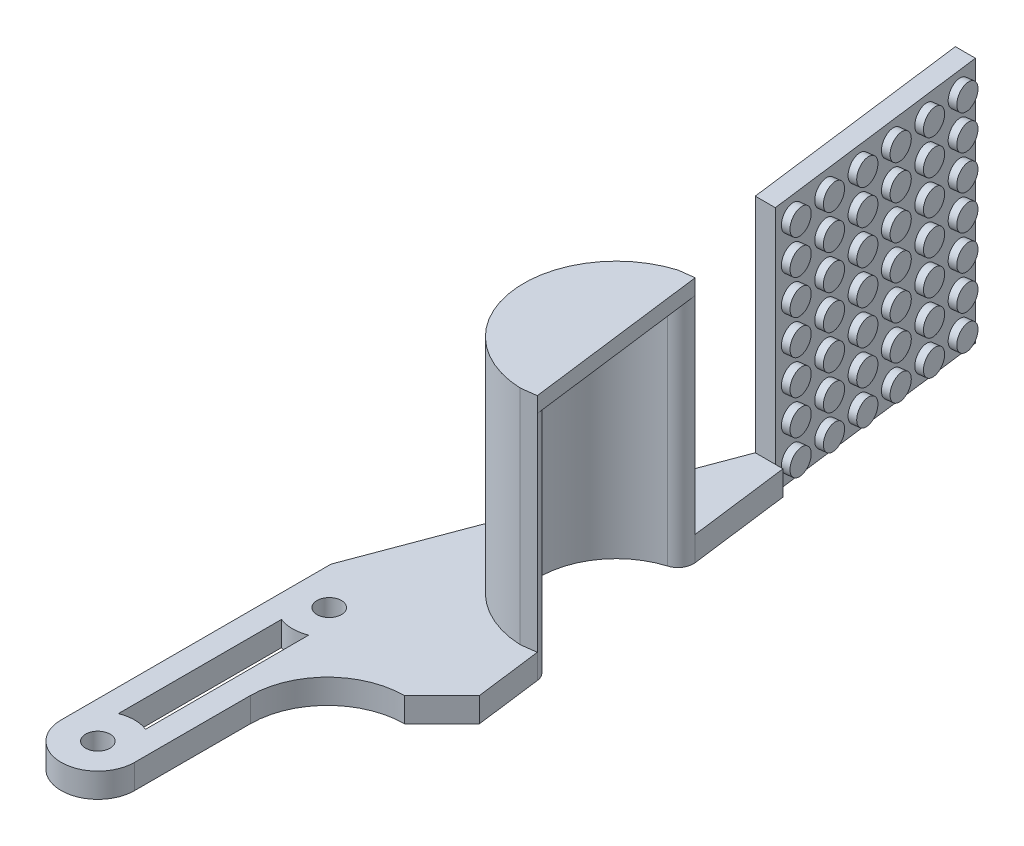
from build123d import *
from build123d.topology import SkipClean

# Parameters (mm, degrees)
CROQUIS1_R              = 1.5875
SALIENTE_EXTRUIR1_DEPTH = 3.175
CORTAR_EXTRUIR1_DEPTH   = 3.175
CORTAR_EXTRUIR3_DEPTH   = 10
CROQUIS4_R              = 10
CORTAR_EXTRUIR4_DEPTH   = 10
REDONDEO1_R             = 2
BOSS_EXTRUDE1_DEPTH     = 26.82
BOSS_EXTRUDE2_DEPTH     = 2
BOSS_EXTRUDE3_DEPTH     = 31.995
SKETCH5_R               = 1.59
BOSS_EXTRUDE4_DEPTH     = 1


with BuildPart() as part:
    # Croquis1 → Saliente-Extruir1 (new body)
    with BuildSketch(Plane(origin=(0, 0, 0), x_dir=(1, 0, 0), z_dir=(0, 1, 0))):
        with BuildLine():
            Line((-12.5, 0), (-12.5, -40))
            Line((-12.5, -40), (-2.975, -40))
            Line((-2.975, -40), (-2.975, -20))
            ThreePointArc((-2.975, -20), (-0.046067812, -12.928932188), (7.025, -10))
            Line((7.025, -10), (12.5, -10))
            Line((12.5, -10), (12.5, 40))
            Line((12.5, 40), (2.5, 40))
            Line((2.5, 40), (-12.5, 0))
        make_face()
        with Locations(Location((-7.7375, -5, 0), (0, 0, 270))):
            Circle(CROQUIS1_R, mode=Mode.SUBTRACT)
        with Locations(Location((-7.7375, -35, 0), (0, 0, 270))):
            Circle(CROQUIS1_R, mode=Mode.SUBTRACT)
    extrude(amount=SALIENTE_EXTRUIR1_DEPTH)

    # Croquis2 → Cortar-Extruir1 (cut)
    with BuildSketch(Plane(origin=(0, 3.175, 0), x_dir=(1, 0, 0), z_dir=(0, 1, 0))):
        Polygon((12.5, -10), (6.1, 40), (12.5, 40), align=None)
    extrude(amount=-CORTAR_EXTRUIR1_DEPTH, mode=Mode.SUBTRACT)

    # Croquis3 → Cortar-Extruir3 (cut)
    with BuildSketch(Plane(origin=(0, 3.175, 0), x_dir=(1, 0, 0), z_dir=(0, 1, 0))):
        with BuildLine():
            ThreePointArc((-5.975, -30.575635639), (-7.7375, -30.2375), (-9.5, -30.575635639))
            Line((-9.5, -30.575635639), (-9.5, -9.427055314))
            ThreePointArc((-9.5, -9.427055314), (-7.7375, -9.765), (-5.975, -9.427055314))
            Line((-5.975, -9.427055314), (-5.975, -14.803847577))
            Line((-5.975, -14.803847577), (-5.975, -30.575635639))
        make_face()
        with BuildLine():
            ThreePointArc((-12.5, -35), (-7.7375, -39.7625), (-2.975, -35))
            Line((-2.975, -35), (-2.975, -40))
            Line((-2.975, -40), (-12.5, -40))
            Line((-12.5, -40), (-12.5, -35))
        make_face()
    extrude(amount=-CORTAR_EXTRUIR3_DEPTH, mode=Mode.SUBTRACT)

    # Croquis4 → Cortar-Extruir4 (cut)
    with BuildSketch(Plane(origin=(0, 3.175, 0), x_dir=(1, 0, 0), z_dir=(0, 1, 0))):
        with Locations((9.274103387, 15.202317292)):
            Circle(CROQUIS4_R)
        Polygon((7.025, -10), (11.878723404, -5.146276596), (12.5, -10), align=None)
    extrude(amount=-CORTAR_EXTRUIR4_DEPTH, mode=Mode.SUBTRACT)

    # Redondeo1
    redondeo1_edges = [part.edges().sort_by_distance(p)[0] for p in [
        (8.004462032, 1.5875, -25.121390375),
        (10.543744741, 1.5875, -5.283244209),
    ]]
    fillet(redondeo1_edges, radius=REDONDEO1_R)

    # Sketch1 → Boss-Extrude1 (add)
    with SkipClean():  # the faces are left unmerged after this step: merging them gives an invalid solid
        with BuildSketch(Plane(origin=(0, 3.175, 0), x_dir=(1, 0, 0), z_dir=(0, 1, 0))):
            with BuildLine():
                Line((7.771843477, 26.938722839), (5.78802886, 26.684794568))
                ThreePointArc((5.78802886, 26.684794568), (-2.628784313, 13.678747666), (8.79254868, 3.211983474))
                Line((8.79254868, 3.211983474), (10.776363297, 3.465911745))
                ThreePointArc((10.776363297, 3.465911745), (10.143802127, 4.686471223), (8.872807798, 5.210372444))
                ThreePointArc((8.872807798, 5.210372444), (-0.644969697, 13.932675937), (6.369041281, 24.771048355))
                ThreePointArc((6.369041281, 24.771048355), (7.467102295, 25.59818866), (7.771843477, 26.938722839))
            make_face()
        extrude(amount=BOSS_EXTRUDE1_DEPTH)

    # Sketch2 → Boss-Extrude2 (add)
    with SkipClean():  # the faces are left unmerged after this step: merging them gives an invalid solid
        with BuildSketch(Plane(origin=(0, 29.995, 0), x_dir=(1, 0, 0), z_dir=(0, 1, 0))):
            with BuildLine():
                Line((10.776363297, 3.465911745), (7.771843477, 26.938722839))
                Line((7.771843477, 26.938722839), (5.78802886, 26.684794568))
                ThreePointArc((5.78802886, 26.684794568), (-2.628784313, 13.678747666), (8.79254868, 3.211983474))
                Line((8.79254868, 3.211983474), (10.776363297, 3.465911745))
            make_face()
        extrude(amount=BOSS_EXTRUDE2_DEPTH)

    # Sketch4 → Boss-Extrude3 (add)
    with SkipClean():  # the faces are left unmerged after this step: merging them gives an invalid solid
        with BuildSketch(Plane.XZ):
            Polygon((1.291075936, -69.75721925), (-1.308924064, -69.75721925), (2.5, -40), (5.1, -40), align=None)
        extrude(amount=-BOSS_EXTRUDE3_DEPTH)

    # Sketch5 → Boss-Extrude4 (add)
    with SkipClean():  # the faces are left unmerged after this step: merging them gives an invalid solid
        with BuildSketch(Plane(origin=(10.055254707, 0, -1.287072602), x_dir=(-0.12696413546540494, 0, -0.9919073083234755), z_dir=(0.9919073083234755, 0, -0.12696413546540494))):
            with Locations((41.528775242, 29.495)):
                Circle(SKETCH5_R)
            with Locations((46.528775242, 29.495)):
                Circle(SKETCH5_R)
            with Locations((51.528775242, 29.495)):
                Circle(SKETCH5_R)
            with Locations((56.528775242, 29.495)):
                Circle(SKETCH5_R)
            with Locations((61.528775242, 29.495)):
                Circle(SKETCH5_R)
            with Locations((66.528775242, 29.495)):
                Circle(SKETCH5_R)
            with Locations((46.528775242, 24.995)):
                Circle(SKETCH5_R)
            with Locations((51.528775242, 24.995)):
                Circle(SKETCH5_R)
            with Locations((56.528775242, 24.995)):
                Circle(SKETCH5_R)
            with Locations((61.528775242, 24.995)):
                Circle(SKETCH5_R)
            with Locations((66.528775242, 24.995)):
                Circle(SKETCH5_R)
            with Locations((46.528775242, 20.495)):
                Circle(SKETCH5_R)
            with Locations((51.528775242, 20.495)):
                Circle(SKETCH5_R)
            with Locations((56.528775242, 20.495)):
                Circle(SKETCH5_R)
            with Locations((61.528775242, 20.495)):
                Circle(SKETCH5_R)
            with Locations((66.528775242, 20.495)):
                Circle(SKETCH5_R)
            with Locations((46.528775242, 15.995)):
                Circle(SKETCH5_R)
            with Locations((51.528775242, 15.995)):
                Circle(SKETCH5_R)
            with Locations((56.528775242, 15.995)):
                Circle(SKETCH5_R)
            with Locations((61.528775242, 15.995)):
                Circle(SKETCH5_R)
            with Locations((66.528775242, 15.995)):
                Circle(SKETCH5_R)
            with Locations((46.528775242, 11.495)):
                Circle(SKETCH5_R)
            with Locations((51.528775242, 11.495)):
                Circle(SKETCH5_R)
            with Locations((56.528775242, 11.495)):
                Circle(SKETCH5_R)
            with Locations((61.528775242, 11.495)):
                Circle(SKETCH5_R)
            with Locations((66.528775242, 11.495)):
                Circle(SKETCH5_R)
            with Locations((46.528775242, 6.995)):
                Circle(SKETCH5_R)
            with Locations((51.528775242, 6.995)):
                Circle(SKETCH5_R)
            with Locations((56.528775242, 6.995)):
                Circle(SKETCH5_R)
            with Locations((61.528775242, 6.995)):
                Circle(SKETCH5_R)
            with Locations((66.528775242, 6.995)):
                Circle(SKETCH5_R)
            with Locations((46.528775242, 2.495)):
                Circle(SKETCH5_R)
            with Locations((51.528775242, 2.495)):
                Circle(SKETCH5_R)
            with Locations((56.528775242, 2.495)):
                Circle(SKETCH5_R)
            with Locations((61.528775242, 2.495)):
                Circle(SKETCH5_R)
            with Locations((66.528775242, 2.495)):
                Circle(SKETCH5_R)
            with Locations((41.528775242, 24.995)):
                Circle(SKETCH5_R)
            with Locations((41.528775242, 20.495)):
                Circle(SKETCH5_R)
            with Locations((41.528775242, 15.995)):
                Circle(SKETCH5_R)
            with Locations((41.528775242, 11.495)):
                Circle(SKETCH5_R)
            with Locations((41.528775242, 6.995)):
                Circle(SKETCH5_R)
            with Locations((41.528775242, 2.495)):
                Circle(SKETCH5_R)
        extrude(amount=BOSS_EXTRUDE4_DEPTH)


solid = part.part
